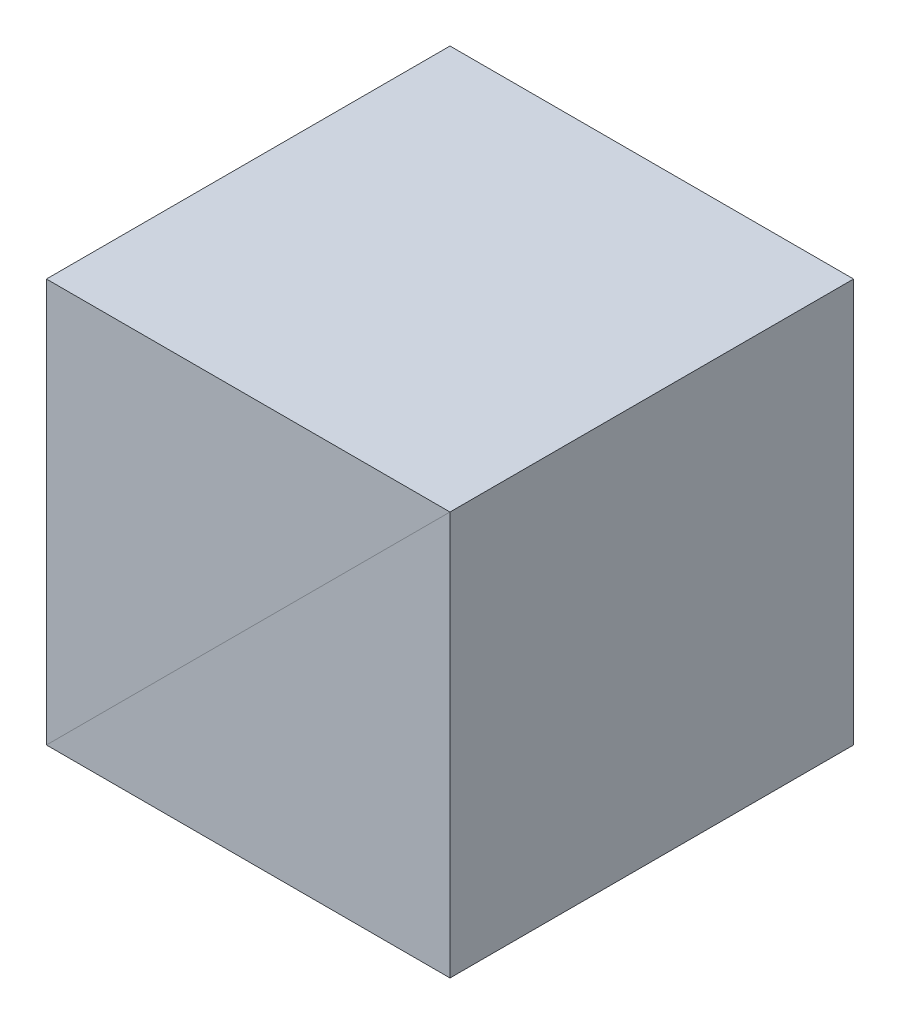
from build123d import *

# Parameters (mm, degrees)
EXTRUDE_1_DEPTH = 7.5


with BuildPart() as part:
    # 草图1 → 凸台-拉伸1 (new body, symmetric)
    with BuildSketch(Plane.XY):
        Polygon((-7.5, -7.5), (7.5, -7.5), (7.5, 7.5), align=None)
    extrude(amount=EXTRUDE_1_DEPTH, both=True)


with BuildPart() as body_2:
    # 镜向2: mirrored copy
    add(part.part.mirror(Plane(origin=(7.5, 7.5, 7.5), x_dir=(0, 0, 1), z_dir=(0.707106781, -0.707106781, 0))))


solid = Compound([part.part, body_2.part])
